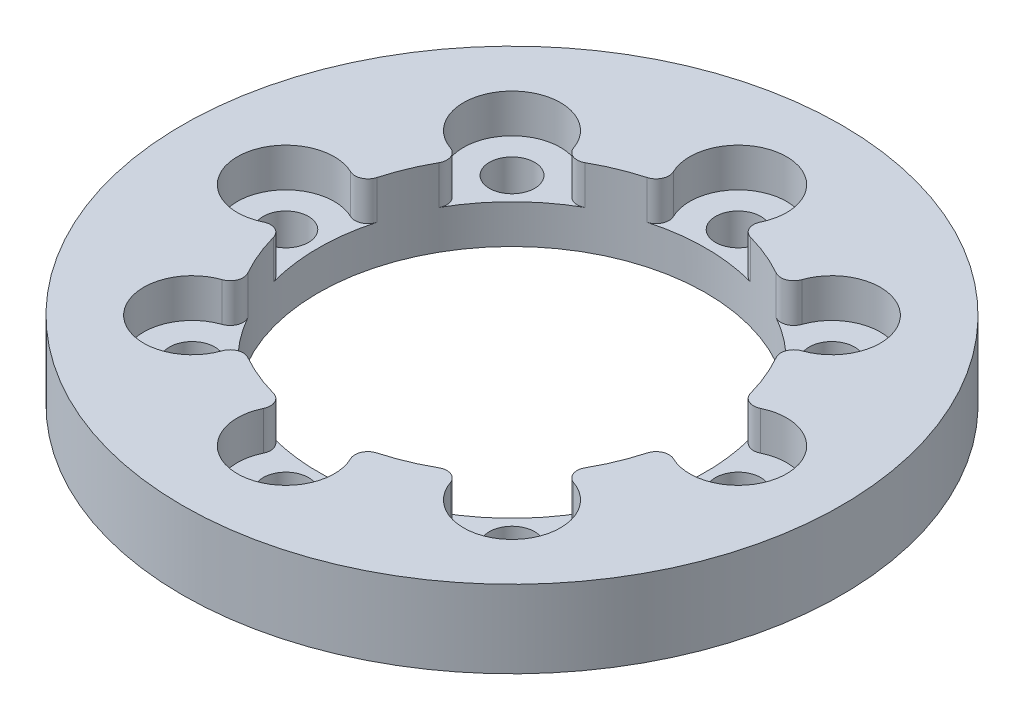
from build123d import *

# Parameters (mm, degrees)
SKETCH1_R           = 25.5
SKETCH1_R_2         = 15
SKETCH1_R_3         = 1.75
BOSS_EXTRUDE1_DEPTH = 6
SKETCH2_R           = 3.75
SKETCH2_R_2         = 1.75
CUT_EXTRUDE1_DEPTH  = 3
FILLET1_R           = 1


with BuildPart() as part:
    # Sketch1 → Boss-Extrude1 (new body)
    with BuildSketch(Plane(origin=(0, 0, 0), x_dir=(1, 0, 0), z_dir=(0, 1, 0))):
        Circle(SKETCH1_R)
        Circle(SKETCH1_R_2, mode=Mode.SUBTRACT)
        with Locations((0, 17.5)):
            Circle(SKETCH1_R_3, mode=Mode.SUBTRACT)
        with Locations((12.374368671, 12.374368671)):
            Circle(SKETCH1_R_3, mode=Mode.SUBTRACT)
        with Locations((17.5, 0)):
            Circle(SKETCH1_R_3, mode=Mode.SUBTRACT)
        with Locations((12.374368671, -12.374368671)):
            Circle(SKETCH1_R_3, mode=Mode.SUBTRACT)
        with Locations((0, -17.5)):
            Circle(SKETCH1_R_3, mode=Mode.SUBTRACT)
        with Locations((-12.374368671, -12.374368671)):
            Circle(SKETCH1_R_3, mode=Mode.SUBTRACT)
        with Locations((-17.5, 0)):
            Circle(SKETCH1_R_3, mode=Mode.SUBTRACT)
        with Locations((-12.374368671, 12.374368671)):
            Circle(SKETCH1_R_3, mode=Mode.SUBTRACT)
    extrude(amount=BOSS_EXTRUDE1_DEPTH)

    # Sketch2 → Cut-Extrude1 (cut)
    with BuildSketch(Plane(origin=(0, 6, 0), x_dir=(1, 0, 0), z_dir=(0, 1, 0))):
        with Locations((-12.374368671, 12.374368671)):
            Circle(SKETCH2_R)
        with Locations((-12.374368671, 12.374368671)):
            Circle(SKETCH2_R_2, mode=Mode.SUBTRACT)
        with Locations((-12.374368671, -12.374368671)):
            Circle(SKETCH2_R)
        with Locations((-12.374368671, -12.374368671)):
            Circle(SKETCH2_R_2, mode=Mode.SUBTRACT)
        with Locations((12.374368671, -12.374368671)):
            Circle(SKETCH2_R)
        with Locations((12.374368671, -12.374368671)):
            Circle(SKETCH2_R_2, mode=Mode.SUBTRACT)
        with Locations((12.374368671, 12.374368671)):
            Circle(SKETCH2_R)
        with Locations((12.374368671, 12.374368671)):
            Circle(SKETCH2_R_2, mode=Mode.SUBTRACT)
        with Locations((0, 17.5)):
            Circle(SKETCH2_R)
        with Locations((0, 17.5)):
            Circle(SKETCH2_R_2, mode=Mode.SUBTRACT)
        with Locations((17.5, 0)):
            Circle(SKETCH2_R)
        with Locations((17.5, 0)):
            Circle(SKETCH2_R_2, mode=Mode.SUBTRACT)
        with Locations((0, -17.5)):
            Circle(SKETCH2_R)
        with Locations((0, -17.5)):
            Circle(SKETCH2_R_2, mode=Mode.SUBTRACT)
        with Locations((-17.5, 0)):
            Circle(SKETCH2_R)
        with Locations((-17.5, 0)):
            Circle(SKETCH2_R_2, mode=Mode.SUBTRACT)
    extrude(amount=-CUT_EXTRUDE1_DEPTH, mode=Mode.SUBTRACT)

    # Fillet1
    fillet1_edges = [part.edges().sort_by_distance(p)[0] for p in [
        (-12.271757971, 4.5, -8.625772794),
        (-8.625772794, 4.5, -12.271757971),
        (-14.776785714, 4.5, 2.578100842),
        (-14.776785714, 4.5, -2.578100842),
        (2.578100842, 4.5, 14.776785714),
        (-2.578100842, 4.5, 14.776785714),
        (14.776785714, 4.5, -2.578100842),
        (14.776785714, 4.5, 2.578100842),
        (-2.578100842, 4.5, -14.776785714),
        (2.578100842, 4.5, -14.776785714),
        (8.625772794, 4.5, -12.271757971),
        (12.271757971, 4.5, -8.625772794),
        (12.271757971, 4.5, 8.625772794),
        (8.625772794, 4.5, 12.271757971),
        (-8.625772794, 4.5, 12.271757971),
        (-12.271757971, 4.5, 8.625772794),
    ]]
    fillet(fillet1_edges, radius=FILLET1_R)


solid = part.part
